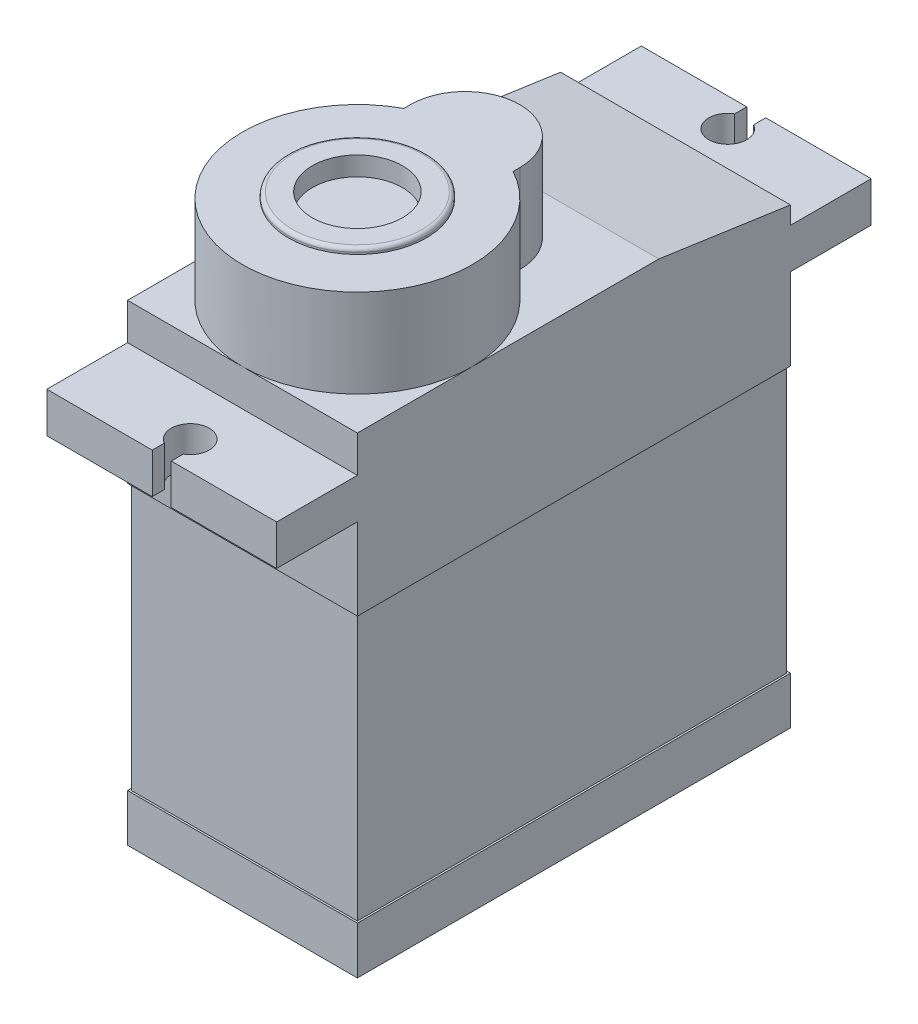
from build123d import *

# Parameters (mm, degrees)
SKETCH1_W           = 12.1
SKETCH1_H           = 22.8
BOSS_EXTRUDE1_DEPTH = 24.85
SKETCH2_OUTSIDE_W   = 31.966
SKETCH2_OUTSIDE_H   = 34.016
CUT_EXTRUDE1_DEPTH  = 24.85
SKETCH3_R           = 2.875
SKETCH3_R_2         = 6.05
BOSS_EXTRUDE2_DEPTH = 4.65
BOSS_EXTRUDE3_START = 20.8
BOSS_EXTRUDE3_DEPTH = 2.12
CUT_EXTRUDE2_START  = -2.5
SKETCH6_W           = 12.1
SKETCH6_H           = 22.8
SKETCH6_W_2         = 11.9
SKETCH6_H_2         = 22.6
CUT_EXTRUDE2_DEPTH  = 14
SKETCH8_R           = 3.625
BOSS_EXTRUDE5_DEPTH = 0.3
FILLET1_R           = 0.2
SKETCH9_R           = 2.375
CUT_EXTRUDE3_DEPTH  = 1


with BuildPart() as part:
    # Sketch1 → Boss-Extrude1 (new body)
    with BuildSketch(Plane(origin=(0, 0, 0), x_dir=(1, 0, 0), z_dir=(0, 1, 0))):
        Rectangle(SKETCH1_W, SKETCH1_H)
    extrude(amount=BOSS_EXTRUDE1_DEPTH)

    # Sketch2 outside → Cut-Extrude1 (cut)
    with BuildSketch(Plane.ZY.offset(6.05)):
        with Locations((0, 12.425)):
            Rectangle(SKETCH2_OUTSIDE_W, SKETCH2_OUTSIDE_H)
        Polygon((-11.4, 23.85), (-4.47179677, 24.85), (11.4, 24.85), (11.4, 0), (-11.4, 0), align=None, mode=Mode.SUBTRACT)
    extrude(amount=-CUT_EXTRUDE1_DEPTH, mode=Mode.SUBTRACT)

    # Sketch3 → Boss-Extrude2 (add)
    with BuildSketch(Plane(origin=(0, 24.85, 0), x_dir=(1, 0, 0), z_dir=(0, 1, 0))):
        with Locations((0, 0.325)):
            Circle(SKETCH3_R)
        with Locations((0, -5.35)):
            Circle(SKETCH3_R_2)
        with BuildLine():
            Line((2.875, -0.026760855), (2.875, 0.325))
            ThreePointArc((2.875, 0.325), (2.869926129, 0.154269175), (2.854722425, -0.015859031))
            ThreePointArc((2.854722425, -0.015859031), (2.864866398, -0.021300297), (2.875, -0.026760855))
        make_face()
        with BuildLine():
            ThreePointArc((-2.854722425, -0.015859031), (-2.869926129, 0.154269175), (-2.875, 0.325))
            Line((-2.875, 0.325), (-2.875, -0.026760855))
            ThreePointArc((-2.875, -0.026760855), (-2.864866398, -0.021300297), (-2.854722425, -0.015859031))
        make_face()
    extrude(amount=BOSS_EXTRUDE2_DEPTH)

    # Sketch4 → Boss-Extrude3 (add)
    with BuildSketch(Plane(origin=(0, 0, 0), x_dir=(1, 0, 0), z_dir=(0, 1, 0)).offset(BOSS_EXTRUDE3_START)):
        with BuildLine():
            Line((-6.05, 15.65), (-6.05, 11.4))
            Line((-6.05, 11.4), (6.05, 11.4))
            Line((6.05, 11.4), (6.05, 15.65))
            Line((6.05, 15.65), (0.5, 15.65))
            Line((0.5, 15.65), (0.5, 15.016025404))
            ThreePointArc((0.5, 15.016025404), (0.866025404, 14.65), (1, 14.15))
            ThreePointArc((1, 14.15), (-0.5, 13.283974596), (-0.5, 15.016025404))
            Line((-0.5, 15.016025404), (-0.5, 15.65))
            Line((-0.5, 15.65), (-6.05, 15.65))
        make_face()
        with BuildLine():
            Line((6.05, -11.4), (-6.05, -11.4))
            Line((-6.05, -11.4), (-6.05, -15.65))
            Line((-6.05, -15.65), (-0.5, -15.65))
            Line((-0.5, -15.65), (-0.5, -15.016025404))
            ThreePointArc((-0.5, -15.016025404), (-0.5, -13.283974596), (1, -14.15))
            ThreePointArc((1, -14.15), (0.866025404, -14.65), (0.5, -15.016025404))
            Line((0.5, -15.016025404), (0.5, -15.65))
            Line((0.5, -15.65), (6.05, -15.65))
            Line((6.05, -15.65), (6.05, -11.4))
        make_face()
    extrude(amount=BOSS_EXTRUDE3_DEPTH)

    # Sketch6 → Cut-Extrude2 (cut)
    with BuildSketch(Plane.XZ.offset(CUT_EXTRUDE2_START)):
        Rectangle(SKETCH6_W, SKETCH6_H)
        Rectangle(SKETCH6_W_2, SKETCH6_H_2, mode=Mode.SUBTRACT)
    extrude(amount=-CUT_EXTRUDE2_DEPTH, mode=Mode.SUBTRACT)

    # Sketch8 → Boss-Extrude5 (add)
    with BuildSketch(Plane(origin=(0, 29.5, 0), x_dir=(1, 0, 0), z_dir=(0, 1, 0))):
        with Locations((0, -5.35)):
            Circle(SKETCH8_R)
    extrude(amount=BOSS_EXTRUDE5_DEPTH)

    # Fillet1
    fillet1_edges = [part.edges().sort_by_distance(p)[0] for p in [
        (-3.625, 29.8, 5.35),
    ]]
    fillet(fillet1_edges, radius=FILLET1_R)

    # Sketch9 → Cut-Extrude3 (cut)
    with BuildSketch(Plane(origin=(0, 29.8, 0), x_dir=(1, 0, 0), z_dir=(0, 1, 0))):
        with Locations((0, -5.35)):
            Circle(SKETCH9_R)
    extrude(amount=-CUT_EXTRUDE3_DEPTH, mode=Mode.SUBTRACT)


solid = part.part
